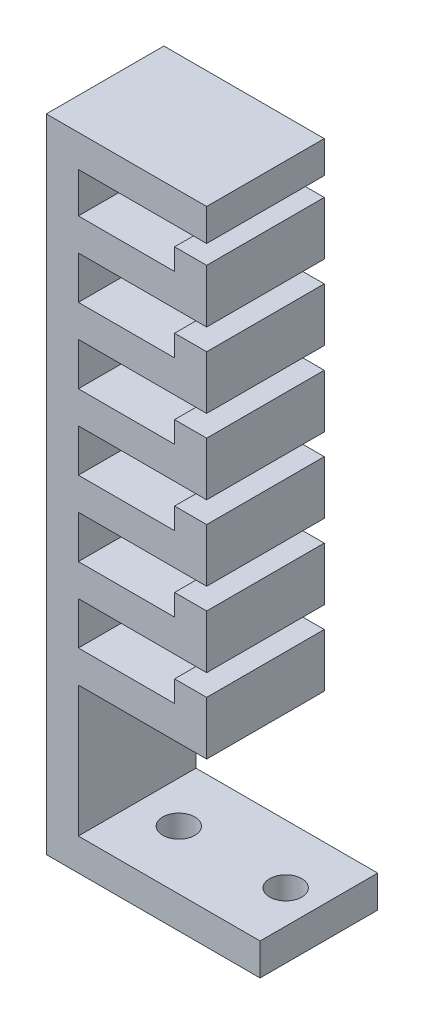
from build123d import *

# Parameters (mm, degrees)
BOSS_EXTRUDE2_DEPTH = 11
SKETCH4_R           = 1.5
CUT_EXTRUDE1_DEPTH  = 11


with BuildPart() as part:
    # Sketch1 → Boss-Extrude2 (new body)
    with BuildSketch(Plane.XY):
        Polygon((0, 0), (-20, 0), (-20, 60), (-17, 60), (-5, 60), (-5, 57), (-17, 57), (-17, 53.232919745), (-8, 53.232919745), (-8, 55.232919745), (-5, 55.232919745), (-5, 50.232919745), (-17, 50.232919745), (-17, 46.232919745), (-8, 46.232919745), (-8, 48.232919745), (-5, 48.232919745), (-5, 43.232919745), (-17, 43.232919745), (-17, 39.232919745), (-8, 39.232919745), (-8, 41.232919745), (-5, 41.232919745), (-5, 36.232919745), (-17, 36.232919745), (-17, 32.232919745), (-8, 32.232919745), (-8, 34.232919745), (-5, 34.232919745), (-5, 29.232919745), (-17, 29.232919745), (-17, 25.232919745), (-8, 25.232919745), (-8, 27.232919745), (-5, 27.232919745), (-5, 22.232919745), (-17, 22.232919745), (-17, 18.232919745), (-8, 18.232919745), (-8, 20.232919745), (-5, 20.232919745), (-5, 15.232919745), (-17, 15.232919745), (-17, 3), (0, 3), align=None)
    extrude(amount=BOSS_EXTRUDE2_DEPTH)

    # Sketch4 → Cut-Extrude1 (cut)
    with BuildSketch(Plane.XZ):
        with Locations((-3.103292827, 5.5)):
            Circle(SKETCH4_R)
        with Locations((-13.103292827, 5.5)):
            Circle(SKETCH4_R)
    extrude(amount=-CUT_EXTRUDE1_DEPTH, mode=Mode.SUBTRACT)


solid = part.part
